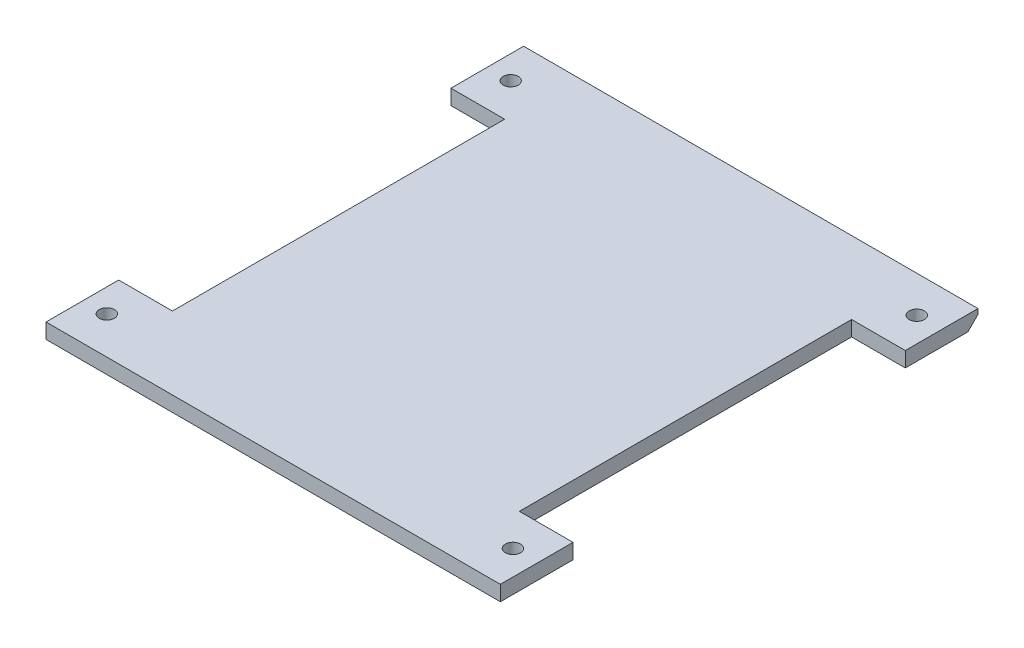
from build123d import *

# Parameters (mm, degrees)
SKETCH2_W           = 90
SKETCH2_H           = 94.61
SKETCH2_R           = 1.5
BOSS_EXTRUDE1_DEPTH = 3
SKETCH3_W           = 10.64
SKETCH3_H           = 65.81
CUT_EXTRUDE1_DEPTH  = 10
CHAMFER1_SIZE       = 2


with BuildPart() as part:
    # Sketch2 → Boss-Extrude1 (new body)
    with BuildSketch(Plane(origin=(0, 0, 0), x_dir=(1, 0, 0), z_dir=(0, 1, 0))):
        Rectangle(SKETCH2_W, SKETCH2_H)
        with Locations((40.082878696, -39.905)):
            Circle(SKETCH2_R, mode=Mode.SUBTRACT)
        with Locations((-40.357121304, -39.905)):
            Circle(SKETCH2_R, mode=Mode.SUBTRACT)
        with Locations((40.082878696, 40.095)):
            Circle(SKETCH2_R, mode=Mode.SUBTRACT)
        with Locations((-40.357121304, 40.095)):
            Circle(SKETCH2_R, mode=Mode.SUBTRACT)
    extrude(amount=BOSS_EXTRUDE1_DEPTH)

    # Sketch3 → Cut-Extrude1 (cut)
    with BuildSketch(Plane(origin=(0, 0, 0), x_dir=(-1, 0, 0), z_dir=(0, -1, 0))):
        with Locations((39.68, 0)):
            Rectangle(SKETCH3_W, SKETCH3_H)
        with Locations((-39.68, 0)):
            Rectangle(SKETCH3_W, SKETCH3_H)
    extrude(amount=-CUT_EXTRUDE1_DEPTH, mode=Mode.SUBTRACT)

    # Chamfer1
    chamfer1_edges = [part.edges().sort_by_distance(p)[0] for p in [
        (0, 0, -47.305),
    ]]
    chamfer(chamfer1_edges, length=CHAMFER1_SIZE)


solid = part.part
